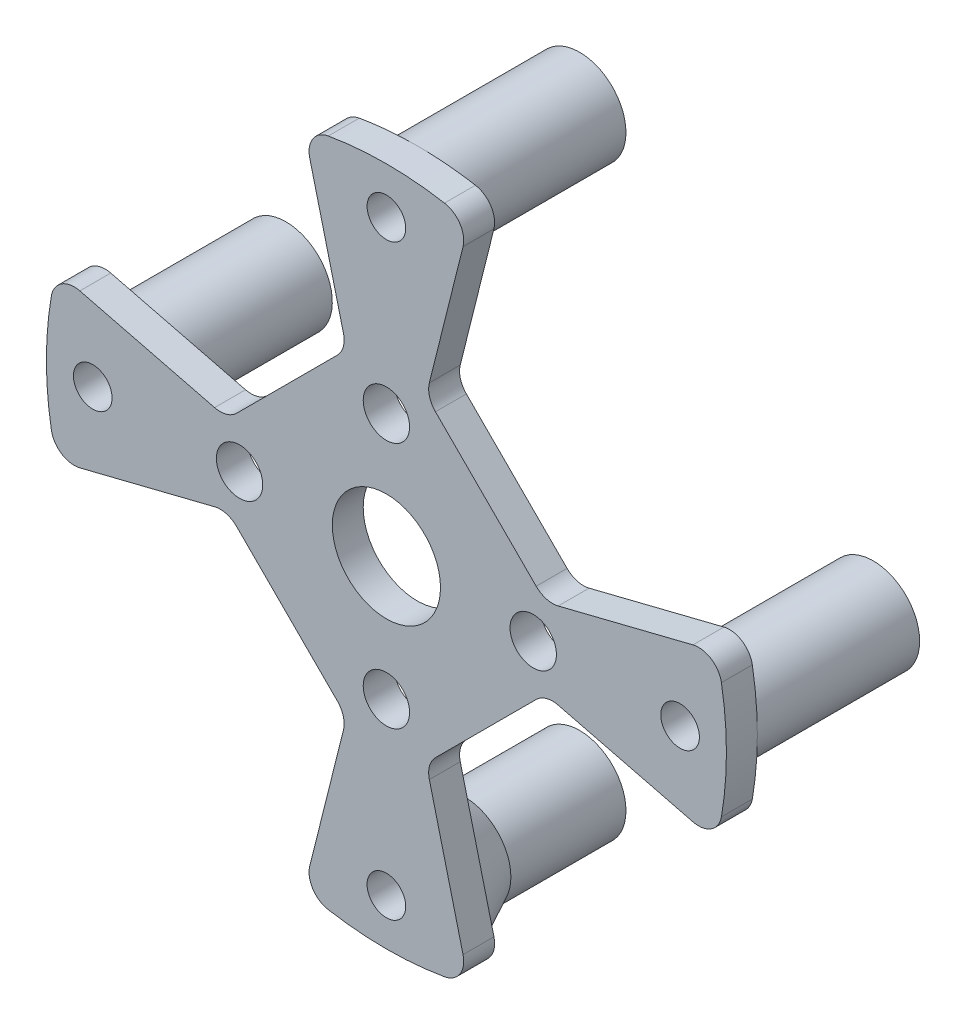
from build123d import *

# Parameters (mm, degrees)
SKETCH_1_R                = 22
EXTRUDE_1_DEPTH           = 2
SKETCH_3_R                = 1.5
CUT_EXTRUDE_1_DEPTH       = 3
SKETCH_4_R                = 3.5
CUT_EXTRUDE_2_DEPTH       = 3
SKETCH_6_R                = 3
EXTRUDE_3_DEPTH           = 10.5
SKETCH_8_R                = 1.25
CUT_EXTRUDE_4_DEPTH       = 12.5
CUT_EXTRUDE_3_DEPTH       = 6
PATTERN_CIRCULAR_1_COUNT  = 4
FILLET_2_R                = 1.5
FILLET_3_R                = 1.5
PATTERN_CIRCULAR_2_COUNT  = 2
REVOLVE_1_ANGLE           = 125
REVOLVE_1_OTHER_WAY_ANGLE = 125


with BuildPart() as part:
    # 草图1 → 凸台-拉伸1 (new body)
    with BuildSketch(Plane.XY):
        Circle(SKETCH_1_R)
    extrude(amount=EXTRUDE_1_DEPTH)

    # 草图3 → 切除-拉伸1 (cut)
    with BuildSketch(Plane(origin=(0, 0, 0), x_dir=(-1, 0, 0), z_dir=(0, 0, -1))):
        with Locations((9.5, 0)):
            Circle(SKETCH_3_R)
        with Locations((0, 8)):
            Circle(SKETCH_3_R)
    cut_extrude_1 = extrude(amount=-CUT_EXTRUDE_1_DEPTH, mode=Mode.SUBTRACT)

    # 草图4 → 切除-拉伸2 (cut)
    with BuildSketch(Plane(origin=(0, 0, 0), x_dir=(-1, 0, 0), z_dir=(0, 0, -1))):
        Circle(SKETCH_4_R)
    extrude(amount=-CUT_EXTRUDE_2_DEPTH, mode=Mode.SUBTRACT)

    # 草图6 → 凸台-拉伸3 (add)
    with BuildSketch(Plane(origin=(0, 0, 0), x_dir=(-1, 0, 0), z_dir=(0, 0, -1))):
        with Locations((0, -19)):
            Circle(SKETCH_6_R)
    extrude_3 = extrude(amount=EXTRUDE_3_DEPTH)

    # 草图8 → 切除-拉伸4 (cut)
    with BuildSketch(Plane(origin=(0, 0, -10.5), x_dir=(-1, 0, 0), z_dir=(0, 0, -1))):
        with Locations((0, -19)):
            Circle(SKETCH_8_R)
    cut_extrude_4 = extrude(amount=-CUT_EXTRUDE_4_DEPTH, mode=Mode.SUBTRACT)

    # 草图7 → 切除-拉伸3 (cut)
    with BuildSketch(Plane(origin=(0, 0, 0), x_dir=(-1, 0, 0), z_dir=(0, 0, -1))):
        Polygon((-2.572740594, 10.290962376), (-10.290962376, 2.572740594), (-30.512752563, 7.628188141), (-7.628188141, 30.512752563), align=None)
    cut_extrude_3 = extrude(amount=-CUT_EXTRUDE_3_DEPTH, mode=Mode.SUBTRACT)

    # 阵列(圆周)1: 凸台-拉伸3, 切除-拉伸4, 切除-拉伸3 ×4 about axis
    pattern_circular_1_axis = Axis((0, 0, 0), (0, 0, 1))
    for i in range(1, PATTERN_CIRCULAR_1_COUNT):
        add(extrude_3.rotate(pattern_circular_1_axis, i * 360 / PATTERN_CIRCULAR_1_COUNT))
        add(cut_extrude_4.rotate(pattern_circular_1_axis, i * 360 / PATTERN_CIRCULAR_1_COUNT), mode=Mode.SUBTRACT)
        add(cut_extrude_3.rotate(pattern_circular_1_axis, i * 360 / PATTERN_CIRCULAR_1_COUNT), mode=Mode.SUBTRACT)

    # 圆角2
    fillet_2_edges = [part.edges().sort_by_distance(p)[0] for p in [
        (21.343135003, -5.335783751, 1),
        (5.335783751, -21.343135003, 1),
        (5.335783751, 21.343135003, 1),
        (21.343135003, 5.335783751, 1),
        (-21.343135003, 5.335783751, 1),
        (-5.335783751, 21.343135003, 1),
        (-5.335783751, -21.343135003, 1),
        (-21.343135003, -5.335783751, 1),
    ]]
    fillet(fillet_2_edges, radius=FILLET_2_R)

    # 圆角3
    fillet_3_edges = [part.edges().sort_by_distance(p)[0] for p in [
        (2.572740594, -10.290962376, 1),
        (10.290962376, -2.572740594, 1),
        (10.290962376, 2.572740594, 1),
        (2.572740594, 10.290962376, 1),
        (-2.572740594, 10.290962376, 1),
        (-10.290962376, 2.572740594, 1),
        (-10.290962376, -2.572740594, 1),
        (-2.572740594, -10.290962376, 1),
    ]]
    fillet(fillet_3_edges, radius=FILLET_3_R)

    # 阵列(圆周)2: 切除-拉伸1 ×2 about axis
    pattern_circular_2_axis = Axis((0, 0, 0), (0, 0, 1))
    for i in range(1, PATTERN_CIRCULAR_2_COUNT):
        add(cut_extrude_1.rotate(pattern_circular_2_axis, i * 360 / PATTERN_CIRCULAR_2_COUNT), mode=Mode.SUBTRACT)

    # 草图10 → 旋转1 (revolve)
    with BuildSketch(Plane(origin=(0, 0, 0), x_dir=(0, 0, -1), z_dir=(1, 0, 0))):
        Polygon((0, -16.312681485), (0, -14.5), (3.69057161, -16.312681485), align=None)
    revolve(axis=Axis((0, -19, 2), (0, 0, -1)), revolution_arc=REVOLVE_1_ANGLE)

    # 草图10 → 旋转1 other way (revolve)
    with BuildSketch(Plane(origin=(0, 0, 0), x_dir=(0, 0, -1), z_dir=(1, 0, 0))):
        Polygon((0, -16.312681485), (0, -14.5), (3.69057161, -16.312681485), align=None)
    revolve(axis=Axis((0, -19, 2), (0, 0, 1)), revolution_arc=REVOLVE_1_OTHER_WAY_ANGLE)


solid = part.part
